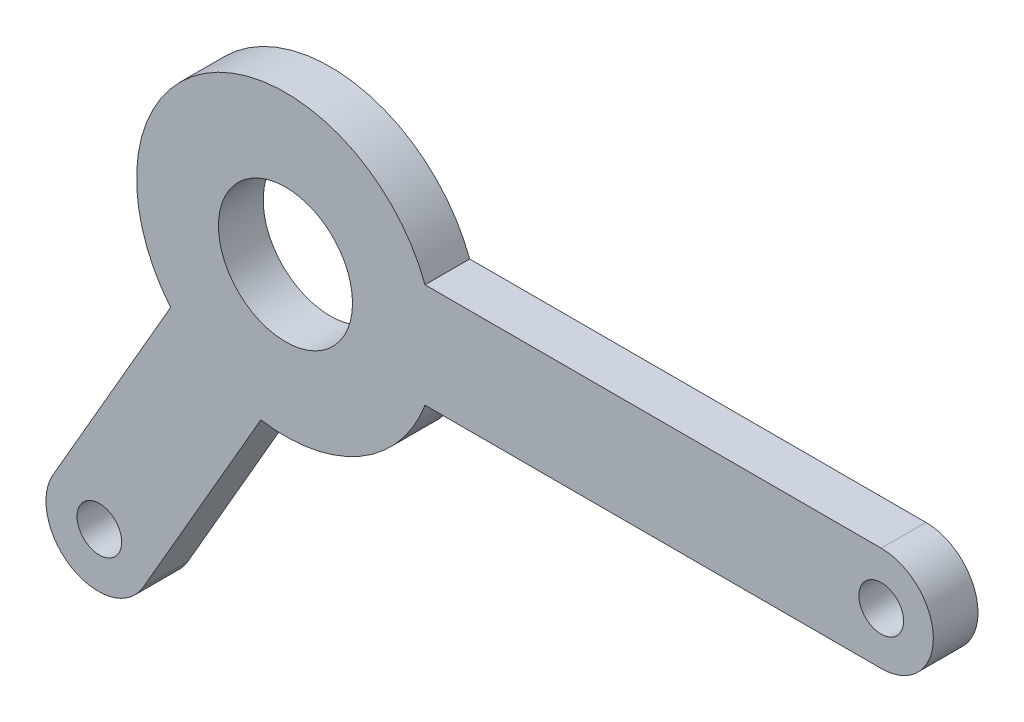
from build123d import *

# Parameters (mm, degrees)
SKETCH1_R           = 22.5
SKETCH1_R_2         = 7.5
BOSS_EXTRUDE1_DEPTH = 15


with BuildPart() as part:
    # Sketch1 → Boss-Extrude1 (new body)
    with BuildSketch(Plane.XY):
        with BuildLine():
            Line((-8.263297928, -49.312451849), (-47.771204936, -117.742154088))
            ThreePointArc((-47.771204936, -117.742154088), (-71.676649502, -124.147598654), (-78.082094069, -100.242154088))
            Line((-78.082094069, -100.242154088), (-38.57418706, -31.812451849))
            ThreePointArc((-38.57418706, -31.812451849), (-25, 43.301270189), (46.837484988, 17.5))
            Line((46.837484988, 17.5), (200, 17.5))
            ThreePointArc((200, 17.5), (217.5, 0), (200, -17.5))
            Line((200, -17.5), (46.837484988, -17.5))
            ThreePointArc((46.837484988, -17.5), (25, -43.301270189), (-8.263297928, -49.312451849))
        make_face()
        Circle(SKETCH1_R, mode=Mode.SUBTRACT)
        with Locations((200, 0)):
            Circle(SKETCH1_R_2, mode=Mode.SUBTRACT)
        with Locations((-62.5, -108.253175473)):
            Circle(SKETCH1_R_2, mode=Mode.SUBTRACT)
    extrude(amount=BOSS_EXTRUDE1_DEPTH)


solid = part.part
